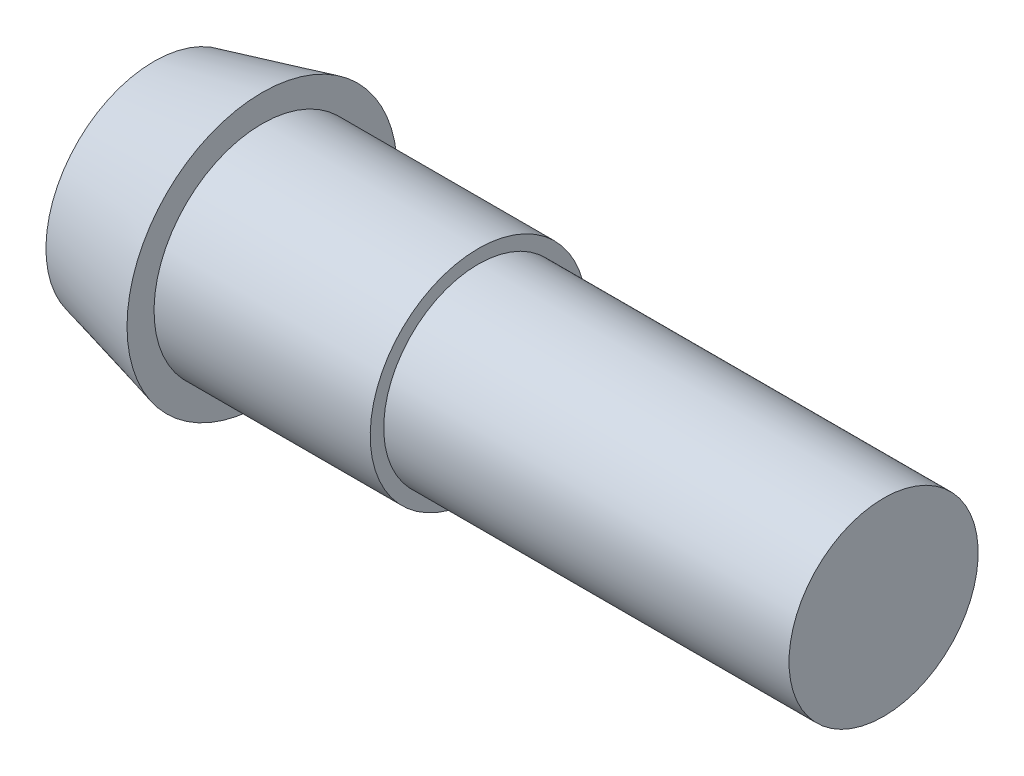
from build123d import *


with BuildPart() as part:
    # Эскиз1 → Повернуть1 (revolve)
    with BuildSketch(Plane.XY):
        Polygon((0, 0), (0, 4), (4, 5), (4, 4), (12, 4), (12, 3.5), (27, 3.5), (27, 0), align=None)
    revolve(axis=Axis((27, 0, 0), (-1, 0, 0)))


solid = part.part
